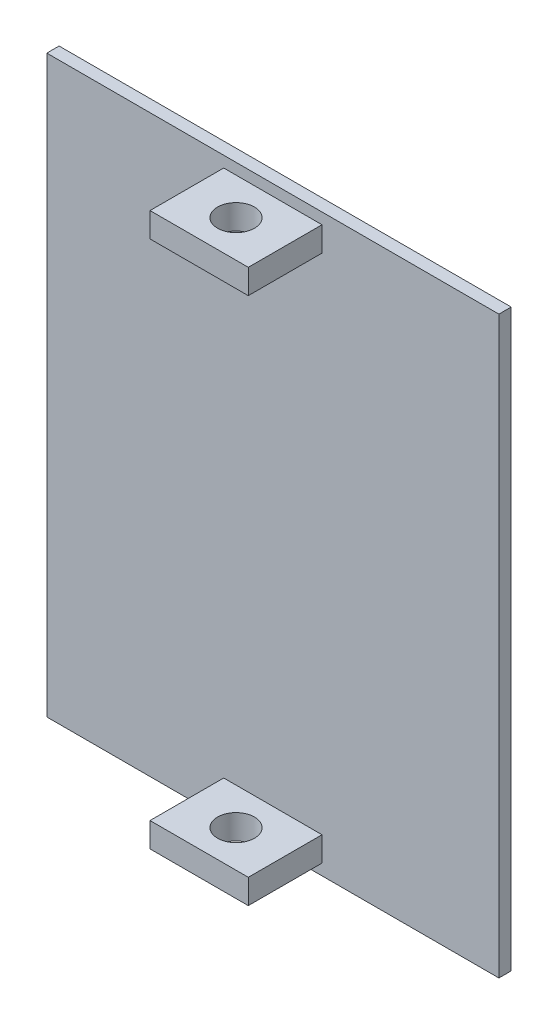
from build123d import *

# Parameters (mm, degrees)
CROQUIS1_W              = 36.8
CROQUIS1_H              = 46.8
SALIENTE_EXTRUIR1_DEPTH = 1
CROQUIS2_W              = 8
CROQUIS2_H              = 2
SALIENTE_EXTRUIR2_DEPTH = 7
CROQUIS2_3_W            = 8
CROQUIS2_3_H            = 2
SALIENTE_EXTRUIR3_DEPTH = 7
CROQUIS6_R              = 1.5
CORTAR_EXTRUIR1_DEPTH   = 50.943668267


with BuildPart() as part:
    # Croquis1 → Saliente-Extruir1 (new body)
    with BuildSketch(Plane.XY):
        Rectangle(CROQUIS1_W, CROQUIS1_H)
    extrude(amount=SALIENTE_EXTRUIR1_DEPTH)

    # Croquis2 → Saliente-Extruir2 (add)
    with BuildSketch(Plane.XY):
        with Locations((0, 21.5)):
            Rectangle(CROQUIS2_W, CROQUIS2_H)
    extrude(amount=SALIENTE_EXTRUIR2_DEPTH)

    # Croquis2_3 → Saliente-Extruir3 (add)
    with BuildSketch(Plane.XY):
        with Locations((0, -21.5)):
            Rectangle(CROQUIS2_3_W, CROQUIS2_3_H)
    extrude(amount=SALIENTE_EXTRUIR3_DEPTH)

    # Croquis6 → Cortar-Extruir1 (cut, through all)
    with BuildSketch(Plane(origin=(0, 22.5, 0), x_dir=(1, 0, 0), z_dir=(0, 1, 0))):
        with Locations((0, -4)):
            Circle(CROQUIS6_R)
    extrude(amount=-CORTAR_EXTRUIR1_DEPTH, mode=Mode.SUBTRACT)


solid = part.part
